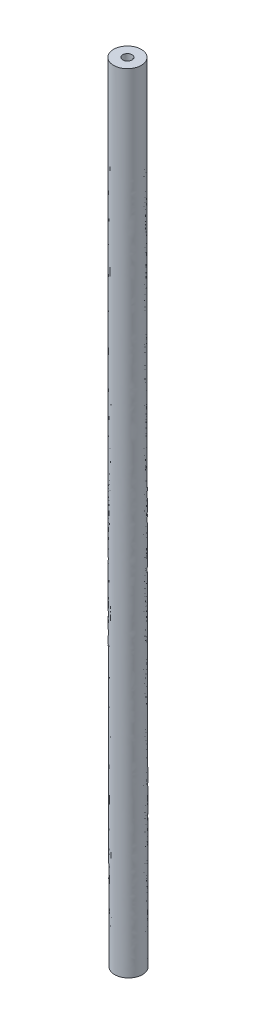
from build123d import *

# Parameters (mm, degrees)
SKETCH1_R   = 1.5
SKETCH1_R_2 = 0.5


with BuildPart() as part:
    # Sweep1: sweep along a path in Sketch2
    with BuildLine(Plane.XY) as sweep1_path:
        Line((0.124999951, -85), (0.062499927, -60))
        ThreePointArc((0.062499927, -60), (0.015624988, -35.000019531), (0, -10))
        Line((0, -10), (0, 0))
    # Sketch1 → Sweep1 (sweep)
    with BuildSketch(Plane(origin=(0, 0, 0), x_dir=(1, 0, 0), z_dir=(0, 1, 0))):
        Circle(SKETCH1_R)
        Circle(SKETCH1_R_2, mode=Mode.SUBTRACT)
    sweep(path=sweep1_path.line)


solid = part.part
